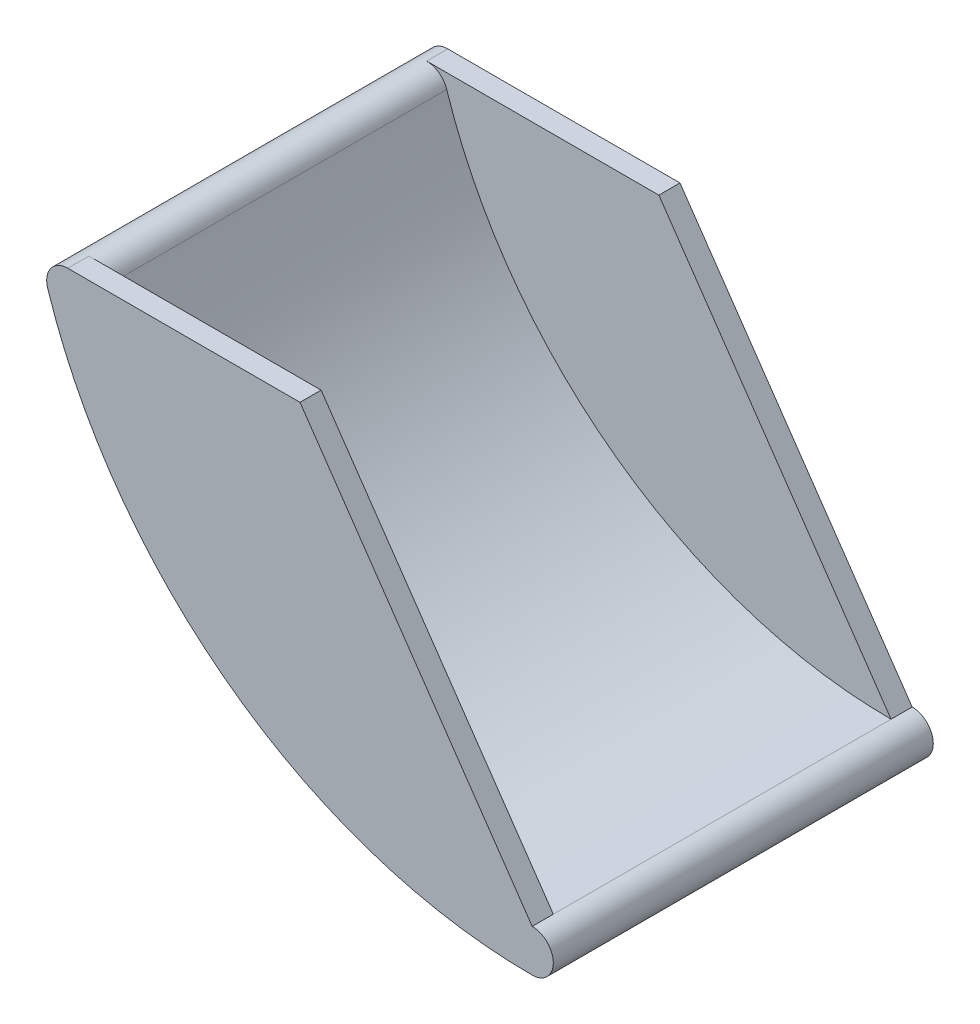
from build123d import *

# Parameters (mm, degrees)
BASE_DEPTH         = 90
WALL_DEPTH         = 10
CUT_EXTRUDE2_DEPTH = 181


with BuildPart() as part:
    # Sketch1 → Base (new body, symmetric)
    with BuildSketch(Plane.XY):
        with BuildLine():
            ThreePointArc((-9.513513741, 156.91891962), (78.103574675, 36.142415178), (220.000000737, -10))
            ThreePointArc((220.000000737, -10), (230, 7.37e-07), (219.999999263, 10))
            ThreePointArc((219.999999263, 10), (89.867008629, 52.317136864), (9.513513741, 163.08108038))
            ThreePointArc((9.513513741, 163.08108038), (-3.08108038, 169.513513741), (-9.513513741, 156.91891962))
        make_face()
    extrude(amount=BASE_DEPTH, both=True)

    # Sketch3 → Wall (add)
    with BuildSketch(Plane.XY.offset(80)):
        with BuildLine():
            Line((0, 170), (219.999999263, 170))
            Line((219.999999263, 170), (219.999999263, 10))
            ThreePointArc((219.999999263, 10), (89.867008629, 52.317136864), (9.513513741, 163.08108038))
            ThreePointArc((9.513513741, 163.08108038), (5.881717275, 168.087360626), (0, 170))
        make_face()
    wall = extrude(amount=WALL_DEPTH)

    # Mirror4: Wall across plane
    add(wall.mirror(Plane(origin=(0, 0, 0), x_dir=(1, 0, 0), z_dir=(0, 0, -1))))

    # Sketch5 → Cut-Extrude2 (cut, through all)
    with BuildSketch(Plane.XY.offset(90)):
        Polygon((219.999999263, 10), (109.999999631, 170), (219.999999263, 170), align=None)
    extrude(amount=-CUT_EXTRUDE2_DEPTH, mode=Mode.SUBTRACT)


solid = part.part
